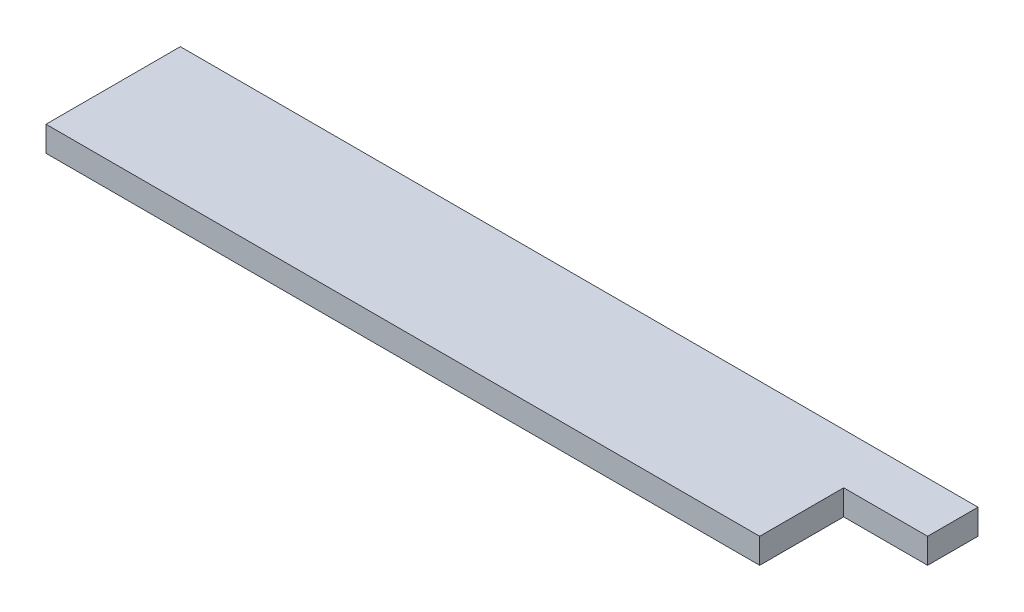
from build123d import *

# Parameters (mm, degrees)
CROQUIS1_W              = 95
CROQUIS1_H              = 16
SALIENTE_EXTRUIR1_DEPTH = 3
CROQUIS2_W              = 10
CROQUIS2_H              = 10
CORTAR_EXTRUIR1_DEPTH   = 10


with BuildPart() as part:
    # Croquis1 → Saliente-Extruir1 (new body)
    with BuildSketch(Plane(origin=(0, 0, 0), x_dir=(1, 0, 0), z_dir=(0, 1, 0))):
        Rectangle(CROQUIS1_W, CROQUIS1_H)
    extrude(amount=SALIENTE_EXTRUIR1_DEPTH)

    # Croquis2 → Cortar-Extruir1 (cut)
    with BuildSketch(Plane(origin=(0, 3, 0), x_dir=(1, 0, 0), z_dir=(0, 1, 0))):
        with Locations((42.5, -3)):
            Rectangle(CROQUIS2_W, CROQUIS2_H)
    extrude(amount=-CORTAR_EXTRUIR1_DEPTH, mode=Mode.SUBTRACT)


solid = part.part
